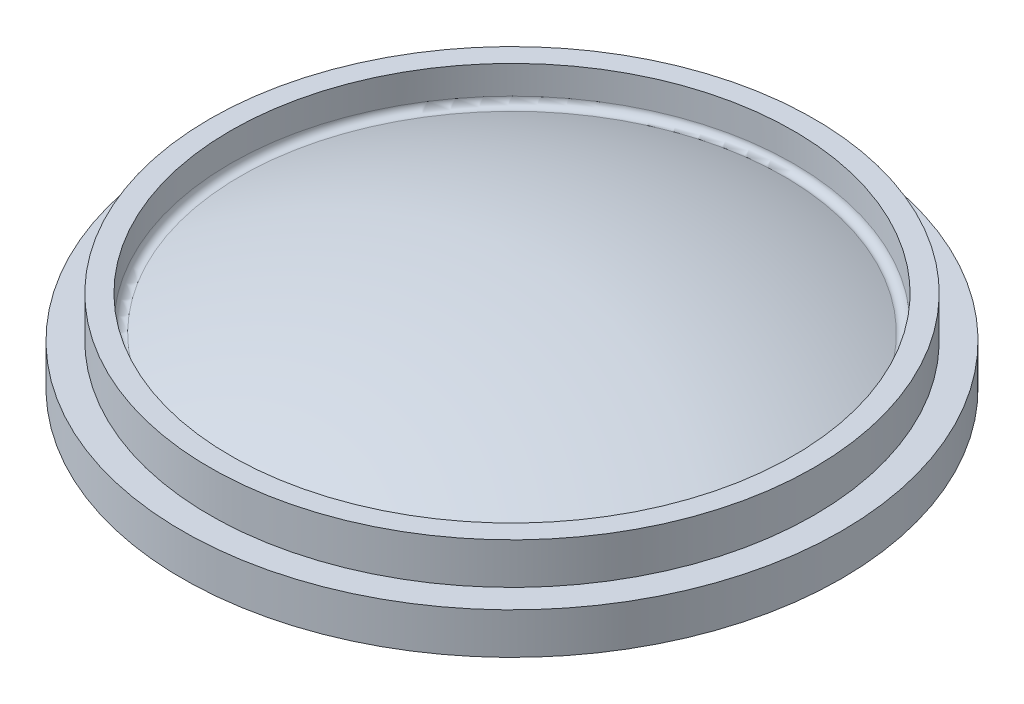
from build123d import *

# Parameters (mm, degrees)
FILLET1_R = 3.175


with BuildPart() as part:
    # Sketch1 → Revolve1 (revolve)
    with BuildSketch(Plane.XY):
        with BuildLine():
            Line((0, 49.2125), (0, 44.45))
            ThreePointArc((0, 44.45), (76.487596697, 34.257888417), (147.6375, 4.392811034))
            Line((147.6375, 4.392811034), (147.6375, 0))
            Line((147.6375, 0), (152.4, 0))
            Line((152.4, 0), (152.4, 19.05))
            Line((152.4, 19.05), (139.7, 19.05))
            Line((139.7, 19.05), (139.7, 38.1))
            Line((139.7, 38.1), (130.175, 38.1))
            Line((130.175, 38.1), (130.175, 20.016399419))
            ThreePointArc((130.175, 20.016399419), (66.704465582, 41.823922564), (0, 49.2125))
        make_face()
    revolve(axis=Axis((0, 49.2125, 0), (0, -1, 0)))

    # Fillet1
    fillet1_edges = [part.edges().sort_by_distance(p)[0] for p in [
        (-130.175, 20.016399419, 0),
    ]]
    fillet(fillet1_edges, radius=FILLET1_R)


solid = part.part
